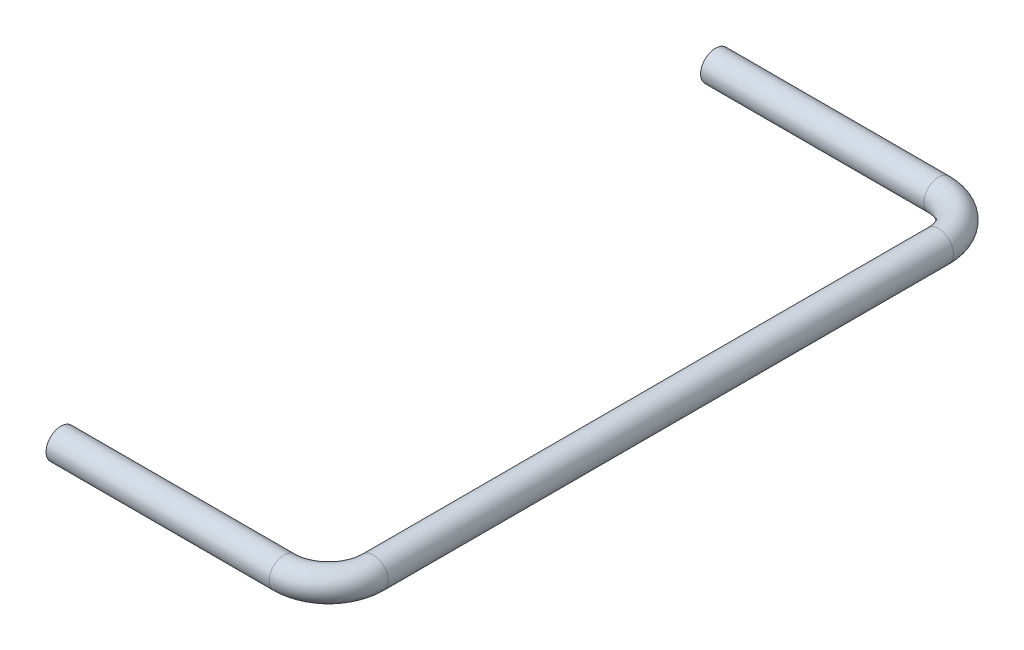
from build123d import *

# Parameters (mm, degrees)
SKETCH_1_R = 1


with BuildPart() as part:
    # По траектории1: sweep along a curve in space
    with BuildLine() as sweep_1_path:
        Line((0, 0, 0), (15, 0, 0))
        ThreePointArc((15, 0, 0), (17.121320344, 0, -0.878679656), (18, 0, -3))
        Line((18, 0, -3), (18, 0, -41))
        ThreePointArc((18, 0, -41), (17.121320344, 0, -43.121320344), (15, 0, -44))
        Line((15, 0, -44), (0, 0, -44))
    # Эскиз1 → По траектории1 (sweep)
    with BuildSketch(Plane(origin=(0, 0, 0), x_dir=(0, 0, -1), z_dir=(1, 0, 0))):
        Circle(SKETCH_1_R)
    sweep(path=sweep_1_path.line)


solid = part.part
